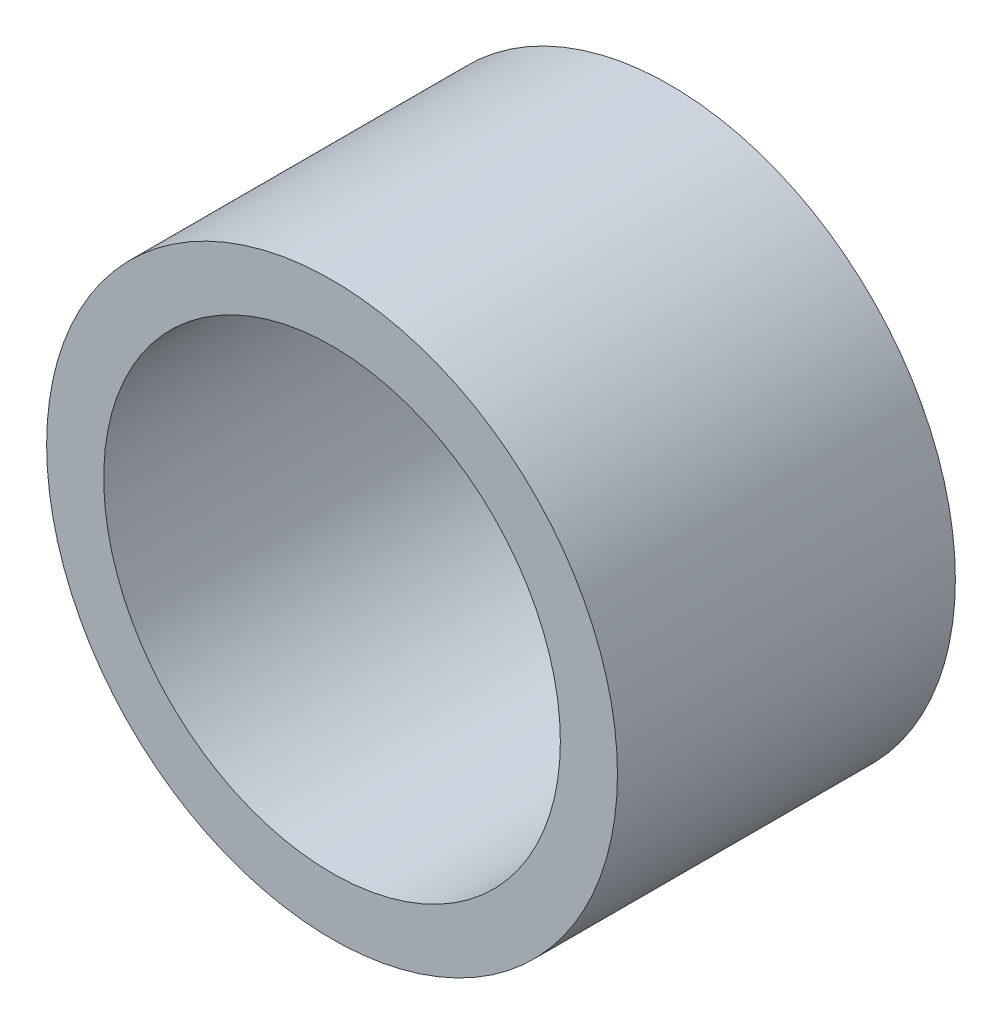
from build123d import *

# Parameters (mm, degrees)
SKETCH1_R      = 3.96875
SKETCH1_R_2    = 3.175
EXTRUDE1_DEPTH = 4.699


with BuildPart() as part:
    # Sketch1 → Extrude1 (new body)
    with BuildSketch(Plane.XY):
        Circle(SKETCH1_R)
        Circle(SKETCH1_R_2, mode=Mode.SUBTRACT)
    extrude(amount=EXTRUDE1_DEPTH)


solid = part.part
